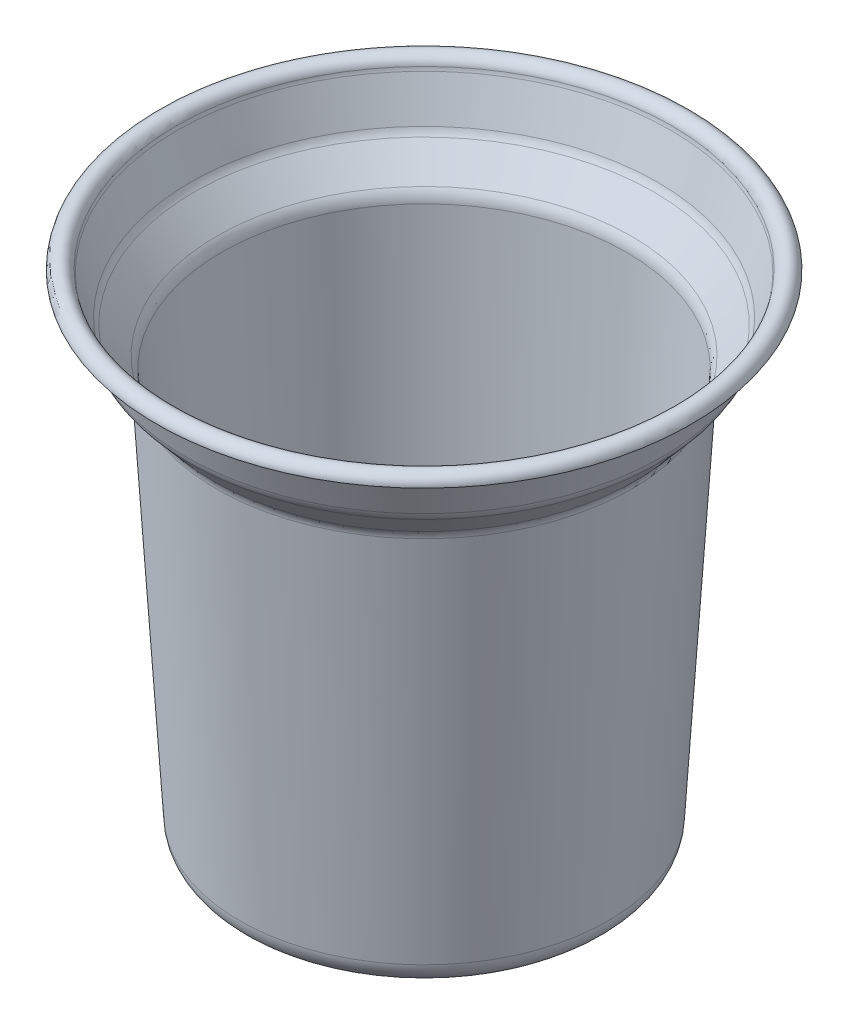
from build123d import *


with BuildPart() as part:
    # Sketch1 → Revolve-Thin1 (revolve)
    with BuildSketch(Plane.XY):
        with BuildLine():
            Line((0, 0), (32.233712481, 0))
            ThreePointArc((32.233712481, 0), (34.975781839, 1.087774797), (36.226474228, 3.759472184))
            Line((36.226474228, 3.759472184), (40.919161137, 81.658074876))
            ThreePointArc((40.919161137, 81.658074876), (41.203824371, 82.917548867), (41.874896475, 84.020712554))
            Line((41.874896475, 84.020712554), (46.490073135, 89.405085325))
            ThreePointArc((46.490073135, 89.405085325), (46.933846353, 90.037455559), (47.247779918, 90.743339754))
            Line((47.247779918, 90.743339754), (49.850562276, 98.551686827))
            ThreePointArc((49.850562276, 98.551686827), (49.951280233, 98.90804941), (50.018609695, 99.272199297))
            ThreePointArc((50.018609695, 99.272199297), (52.136417354, 100.995342152), (54, 99))
            Line((54, 99), (53, 99))
            ThreePointArc((53, 99), (52.068208677, 99.997671076), (51.009304847, 99.136099649))
            ThreePointArc((51.009304847, 99.136099649), (50.92514302, 98.680912289), (50.799245574, 98.235459061))
            Line((50.799245574, 98.235459061), (48.196463216, 90.427111988))
            ThreePointArc((48.196463216, 90.427111988), (47.80404626, 89.544756744), (47.249329738, 88.754293951))
            Line((47.249329738, 88.754293951), (42.634153077, 83.369921181))
            ThreePointArc((42.634153077, 83.369921181), (42.130849, 82.542548415), (41.917351574, 81.597942922))
            Line((41.917351574, 81.597942922), (37.224664665, 3.69934023))
            ThreePointArc((37.224664665, 3.69934023), (35.661299179, 0.359718496), (32.233712481, -1))
            Line((32.233712481, -1), (0, -1))
            Line((0, -1), (0, 0))
        make_face()
    revolve(axis=Axis((0, -6.727399494, 0), (0, 1, 0)))


solid = part.part
